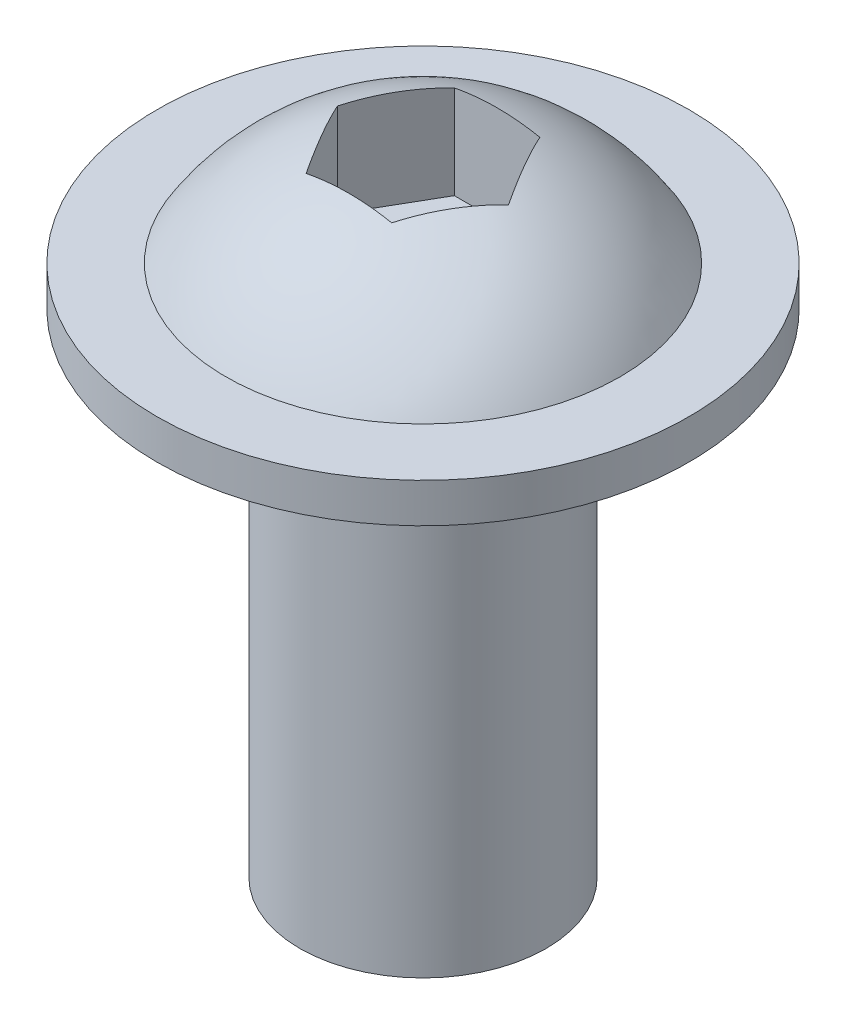
from build123d import *

# Parameters (mm, degrees)
HEX_CUT_DEPTH = 3.175


with BuildPart() as part:
    # Sketch1 → Screw revolve (revolve)
    with BuildSketch(Plane.XY):
        with BuildLine():
            Line((0, 0), (3.96875, 0))
            Line((3.96875, 0), (3.96875, 15.875))
            Line((3.96875, 15.875), (8.5725, 15.875))
            Line((8.5725, 15.875), (8.5725, 17.145))
            Line((8.5725, 17.145), (6.35, 17.145))
            ThreePointArc((6.35, 17.145), (4.603088863, 19.093507399), (2.291358881, 20.32))
            Line((2.291358881, 20.32), (0, 20.32))
            Line((0, 20.32), (0, 0))
        make_face()
    revolve(axis=Axis((0, 0, 0), (0, 1, 0)))

    # Sketch2 → Hex Cut (cut)
    with BuildSketch(Plane(origin=(0, 20.32, 0), x_dir=(-1, 0, 0), z_dir=(0, 1, 0))):
        Polygon((-2.756963005, 0), (-1.378481503, -2.3876), (1.378481503, -2.3876), (2.756963005, 0), (1.378481503, 2.3876), (-1.378481503, 2.3876), align=None)
    extrude(amount=-HEX_CUT_DEPTH, mode=Mode.SUBTRACT)


solid = part.part
